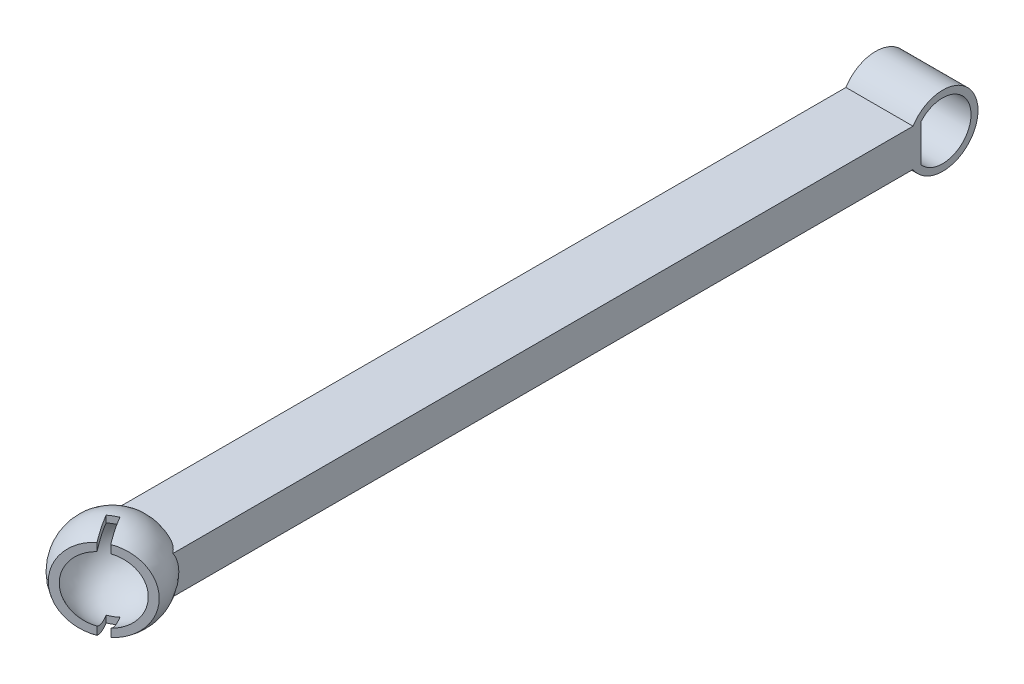
from build123d import *

# Parameters (mm, degrees)
SKETCH_1_W                = 8
SKETCH_1_H                = 12
EXTRUDE_1_DEPTH           = 100
CUT_EXTRUDE_3_DEPTH       = 10
CUT_EXTRUDE_11_DEPTH      = 100
CUT_EXTRUDE_14_DEPTH      = 18
CUT_EXTRUDE_14_DEPTH_BACK = 18
SKETCH_16_W               = 6.416978836
SKETCH_16_H               = 19.46348209
SKETCH_17_W               = 1.2
SKETCH_17_H               = 11.2
CUT_EXTRUDE_15_DEPTH      = 3


with BuildPart() as part:
    # 草图1 → 凸台-拉伸1 (new body)
    with BuildSketch(Plane.XY):
        with Locations((-6.4060213, -18.331726276)):
            Rectangle(SKETCH_1_W, SKETCH_1_H)
    extrude(amount=EXTRUDE_1_DEPTH)

    # 草图5 → 切除-拉伸3 (cut)
    with BuildSketch(Plane.ZY.offset(10.4060213)):
        with BuildLine():
            Line((7.555938676, -20.573863088), (7.555938676, -16.089589464))
            ThreePointArc((7.555938676, -16.089589464), (3.802125111, -15.149730715), (1.6, -18.331726276))
            ThreePointArc((1.6, -18.331726276), (3.802125111, -21.513721837), (7.555938676, -20.573863088))
        make_face()
    extrude(amount=-CUT_EXTRUDE_3_DEPTH, mode=Mode.SUBTRACT)

    # 草图2 → 切除-拉伸11 (cut)
    with BuildSketch(Plane.ZY.offset(10.4060213)):
        with BuildLine():
            Line((0, -12.331726276), (-0.01185689, -12.331726276))
            Line((-0.01185689, -12.331726276), (-0.01185689, -24.331726276))
            Line((-0.01185689, -24.331726276), (0, -24.331726276))
            Line((0, -24.331726276), (22.555938676, -24.331726276))
            Line((22.555938676, -24.331726276), (100, -24.331726276))
            Line((100, -24.331726276), (100.024770408, -20.562939428))
            Line((100.024770408, -20.562939428), (8.52899758, -20.562939428))
            ThreePointArc((8.52899758, -20.562939428), (0.770675983, -18.338179262), (8.522124603, -16.089589464))
            Line((8.522124603, -16.089589464), (100.024770408, -16.089589464))
            Line((100.024770408, -16.089589464), (100, -12.331726276))
            Line((100, -12.331726276), (0, -12.331726276))
        make_face()
    extrude(amount=-CUT_EXTRUDE_11_DEPTH, mode=Mode.SUBTRACT)

    # 草图12 → 旋转3 (revolve)
    with BuildSketch(Plane.XY.offset(100)):
        with BuildLine():
            Line((-6.4060213, -13.526264446), (-6.4060213, -12.726264446))
            ThreePointArc((-6.4060213, -12.726264446), (-12.0060213, -18.326264446), (-6.4060213, -23.926264446))
            Line((-6.4060213, -23.926264446), (-6.4060213, -23.126264446))
            ThreePointArc((-6.4060213, -23.126264446), (-11.2060213, -18.326264446), (-6.4060213, -13.526264446))
        make_face()
    revolve(axis=Axis((-6.4060213, -12.726264446, 100), (0, -1, 0)))

    # 草图12<4> → 切除-旋转1 (revolve, cut)
    with BuildSketch(Plane.XY.offset(100)):
        with BuildLine():
            ThreePointArc((-6.4060213, -13.526264446), (-11.2060213, -18.326264446), (-6.4060213, -23.126264446))
            Line((-6.4060213, -23.126264446), (-6.4060213, -13.526264446))
        make_face()
    revolve(axis=Axis((-6.4060213, -12.726264446, 100), (0, -1, 0)), mode=Mode.SUBTRACT)

    # 草图16 → 切除-拉伸14 (cut, two sides: drawn at the far end of the back side and taken through both)
    with BuildSketch(Plane(origin=(-52.372486851, 0, 30.237269382), x_dir=(0.49999999999999806, 0, 0.8660254037844398), z_dir=(-0.8660254037844397, 0, 0.499999999999998)).offset(-CUT_EXTRUDE_14_DEPTH_BACK)):
        with Locations((89.420800734, -19.375704403)):
            Rectangle(SKETCH_16_W, SKETCH_16_H)
    extrude(amount=CUT_EXTRUDE_14_DEPTH + CUT_EXTRUDE_14_DEPTH_BACK, mode=Mode.SUBTRACT)

    # 草图17 → 切除-拉伸15 (cut)
    with BuildSketch(Plane(origin=(43.106155658, 0, 74.662051718), x_dir=(0.8660254037844397, 0, -0.4999999999999981), z_dir=(0.4999999999999981, 0, 0.8660254037844397))):
        with Locations((-55.537824976, -18.326264446)):
            Rectangle(SKETCH_17_W, SKETCH_17_H)
    extrude(amount=-CUT_EXTRUDE_15_DEPTH, mode=Mode.SUBTRACT)


solid = part.part
